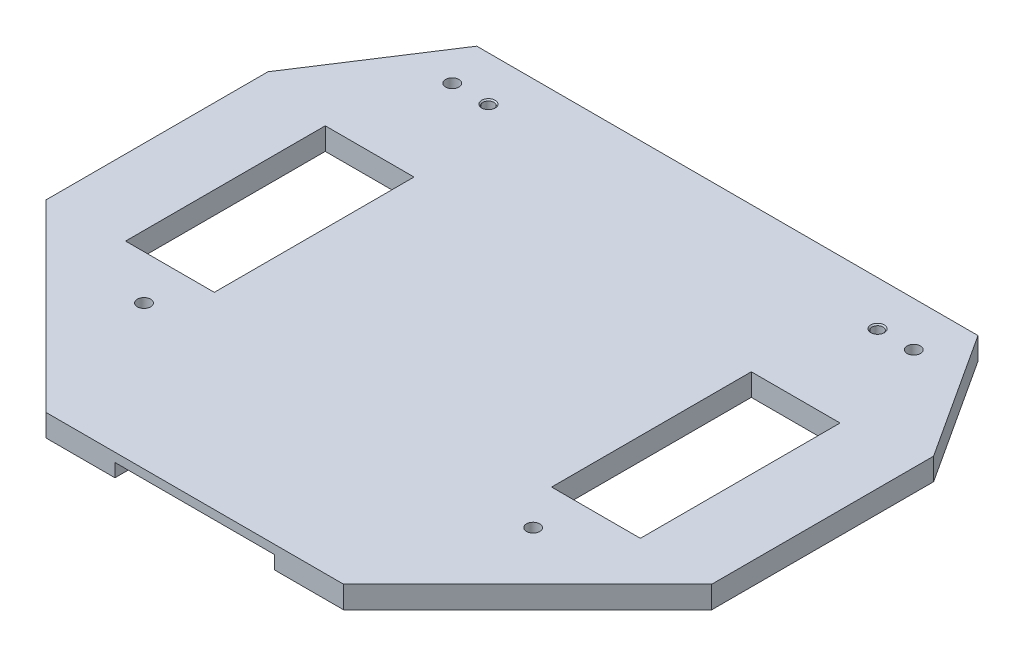
from build123d import *

# Parameters (mm, degrees)
BOSS_EXTRUDE1_DEPTH             = 5
F_3_0_3_DIAMETER_HOLE1_D        = 3
F_3_0_3_DIAMETER_HOLE1_DEPTH    = 6
F_3_0_3_DIAMETER_HOLE1_TIP      = 0.901290929
SKETCH6_W                       = 36
SKETCH6_H                       = 124
CUT_EXTRUDE1_DEPTH              = 3
SKETCH9_W                       = 20
SKETCH9_H                       = 45
CUT_EXTRUDE3_DEPTH              = 6
M3X0_5_TAPPED_HOLE1_D           = 2.5
M3X0_5_TAPPED_HOLE1_DEPTH       = 5
M3X0_5_TAPPED_HOLE1_CSINK_D     = 3.05
M3X0_5_TAPPED_HOLE1_CSINK_ANGLE = 90


with BuildPart() as part:
    # Sketch3 → Boss-Extrude1 (new body)
    with BuildSketch(Plane(origin=(0, -40, 0), x_dir=(-1, 0, 0), z_dir=(0, -1, 0))):
        Polygon((18.468579028, -110), (85.532661839, -110), (127, -68.532661839), (127, -18.529510204), (108.472719443, 10), (-4.471478576, 10), (-23, -18.531420972), (-23, -68.531420972), align=None)
    extrude(amount=BOSS_EXTRUDE1_DEPTH)

    # Ø3.0 (3) Diameter Hole1
    with Locations(Plane(origin=(0, -45, 0), x_dir=(-1, 0, 0), z_dir=(0, -1, 0))):
        with Locations((8.156954779, -77.608240604), (95.838195646, -77.608240604), (103.995150425, 0), (0, 0)):
            Hole(F_3_0_3_DIAMETER_HOLE1_D / 2, depth=F_3_0_3_DIAMETER_HOLE1_DEPTH)
            with Locations((0, 0, -(F_3_0_3_DIAMETER_HOLE1_DEPTH + F_3_0_3_DIAMETER_HOLE1_TIP / 2))):  # 118° drill point
                Cone(0, F_3_0_3_DIAMETER_HOLE1_D / 2, F_3_0_3_DIAMETER_HOLE1_TIP, mode=Mode.SUBTRACT)

    # Sketch6 → Cut-Extrude1 (cut)
    with BuildSketch(Plane(origin=(0, -45, 0), x_dir=(-1, 0, 0), z_dir=(0, -1, 0))):
        with Locations((52, -55)):
            Rectangle(SKETCH6_W, SKETCH6_H)
    extrude(amount=-CUT_EXTRUDE1_DEPTH, mode=Mode.SUBTRACT)

    # Sketch9 → Cut-Extrude3 (cut, through all)
    with BuildSketch(Plane(origin=(0, -45, 0), x_dir=(-1, 0, 0), z_dir=(0, -1, 0))):
        with Locations((4, -45.108240604)):
            Rectangle(SKETCH9_W, SKETCH9_H)
    cut_extrude3 = extrude(amount=-CUT_EXTRUDE3_DEPTH, mode=Mode.SUBTRACT)

    # Mirror1: Cut-Extrude3 across plane
    add(cut_extrude3.mirror(Plane.ZY.offset(52)), mode=Mode.SUBTRACT)

    # M3x0.5 Tapped Hole1
    with Locations(Plane(origin=(0, -40, 0), x_dir=(1, 0, 0), z_dir=(0, 1, 0))):
        with Locations((-8.156954779, 0), (-95.838195646, 0)):
            CounterSinkHole(M3X0_5_TAPPED_HOLE1_D / 2, M3X0_5_TAPPED_HOLE1_CSINK_D / 2, depth=M3X0_5_TAPPED_HOLE1_DEPTH, counter_sink_angle=M3X0_5_TAPPED_HOLE1_CSINK_ANGLE)


solid = part.part
